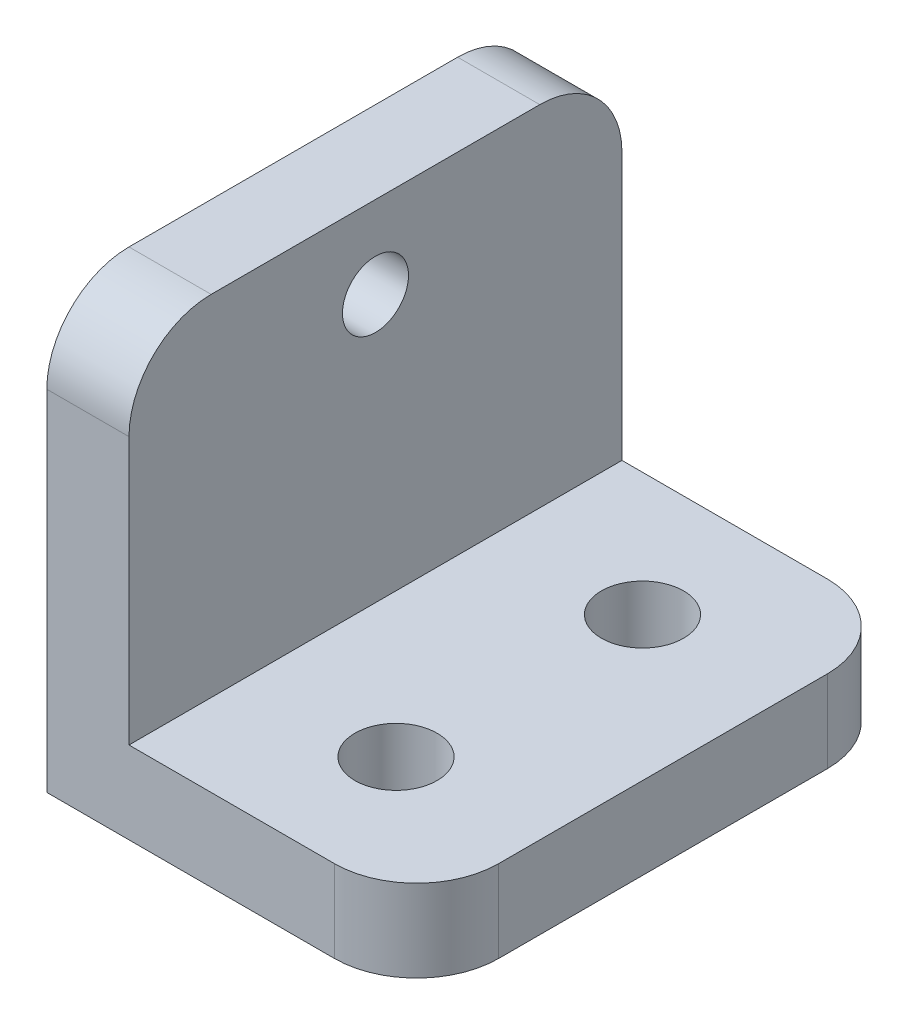
from build123d import *

# Parameters (mm, degrees)
SKETCH8_W                   = 6.35
SKETCH8_H                   = 38.1
SKETCH8_W_2                 = 22.225
BOSS_EXTRUDE2_DEPTH         = 6.35
BOSS_EXTRUDE3_START         = 6.35
SKETCH8_3_W                 = 6.35
SKETCH8_3_H                 = 38.1
BOSS_EXTRUDE3_DEPTH         = 26.9875
F_1_4_0_25_DIAMETER_HOLE2_D = 6.35
F_1_4_20_TAPPED_HOLE1_D     = 5.1054
F_1_4_20_TAPPED_HOLE1_DEPTH = 16.51
F_1_4_20_TAPPED_HOLE1_TIP   = 1.533816902
FILLET1_R                   = 6.35
FILLET2_R                   = 6.35


with BuildPart() as part:
    # Sketch8 → Boss-Extrude2 (new body)
    with BuildSketch(Plane(origin=(0, 0, 0), x_dir=(1, 0, 0), z_dir=(0, 1, 0))):
        with Locations((-11.1125, 0)):
            Rectangle(SKETCH8_W, SKETCH8_H)
        with Locations((3.175, 0)):
            Rectangle(SKETCH8_W_2, SKETCH8_H)
    extrude(amount=BOSS_EXTRUDE2_DEPTH)

    # Sketch8_3 → Boss-Extrude3 (add)
    with BuildSketch(Plane(origin=(0, 0, 0), x_dir=(1, 0, 0), z_dir=(0, 1, 0)).offset(BOSS_EXTRUDE3_START)):
        with Locations((-11.1125, 0)):
            Rectangle(SKETCH8_3_W, SKETCH8_3_H)
    extrude(amount=BOSS_EXTRUDE3_DEPTH)

    # 1_4 _0.25_ Diameter Hole2 (through all)
    with Locations(Plane(origin=(0, 6.35, 0), x_dir=(1, 0, 0), z_dir=(0, 1, 0))):
        with Locations((3.175, -9.525), (3.175, 9.525)):
            Hole(F_1_4_0_25_DIAMETER_HOLE2_D / 2)

    # 1_4-20 Tapped Hole1
    with Locations(Plane(origin=(-7.9375, 0, 0), x_dir=(0, 0, -1), z_dir=(1, 0, 0))):
        with Locations((0, 26.9875)):
            Hole(F_1_4_20_TAPPED_HOLE1_D / 2, depth=F_1_4_20_TAPPED_HOLE1_DEPTH)
            with Locations((0, 0, -(F_1_4_20_TAPPED_HOLE1_DEPTH + F_1_4_20_TAPPED_HOLE1_TIP / 2))):  # 118° drill point
                Cone(0, F_1_4_20_TAPPED_HOLE1_D / 2, F_1_4_20_TAPPED_HOLE1_TIP, mode=Mode.SUBTRACT)

    # Fillet1
    fillet1_edges = [part.edges().sort_by_distance(p)[0] for p in [
        (14.2875, 3.175, -19.05),
        (14.2875, 3.175, 19.05),
    ]]
    fillet(fillet1_edges, radius=FILLET1_R)

    # Fillet2
    fillet2_edges = [part.edges().sort_by_distance(p)[0] for p in [
        (-11.1125, 33.3375, 19.05),
        (-11.1125, 33.3375, -19.05),
    ]]
    fillet(fillet2_edges, radius=FILLET2_R)


solid = part.part
